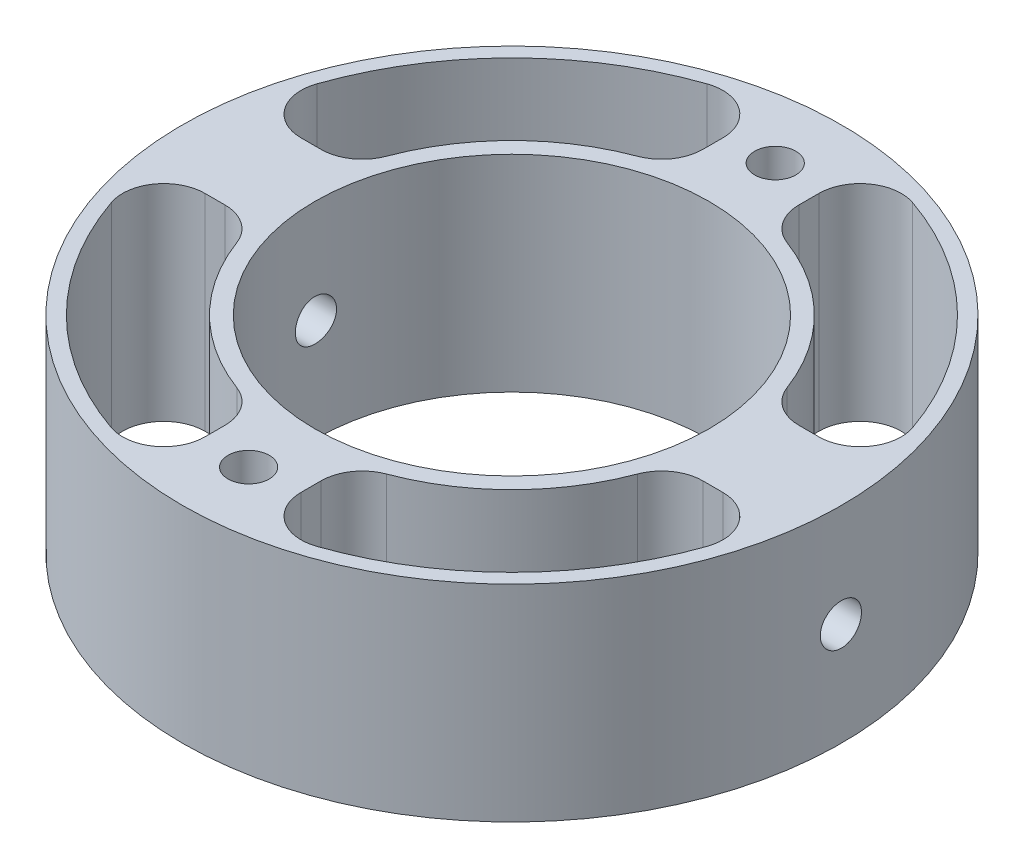
from build123d import *

# Parameters (mm, degrees)
SKETCH3_R           = 24
SKETCH3_R_2         = 14.35
BOSS_EXTRUDE1_DEPTH = 15
CUT_EXTRUDE2_START  = 50
SKETCH4_R           = 1.5
CUT_EXTRUDE2_DEPTH  = 100
SKETCH5_R           = 1.5
CUT_EXTRUDE3_DEPTH  = 100
CUT_EXTRUDE6_DEPTH  = 26
CUT_EXTRUDE7_DEPTH  = 26
CUT_EXTRUDE8_DEPTH  = 26
CUT_EXTRUDE9_DEPTH  = 26
FILLET5_R           = 3


with BuildPart() as part:
    # Sketch3 → Boss-Extrude1 (new body)
    with BuildSketch(Plane(origin=(0, 0, 0), x_dir=(1, 0, 0), z_dir=(0, 1, 0))):
        Circle(SKETCH3_R)
        Circle(SKETCH3_R_2, mode=Mode.SUBTRACT)
    extrude(amount=BOSS_EXTRUDE1_DEPTH)

    # Sketch4 → Cut-Extrude2 (cut)
    with BuildSketch(Plane(origin=(0, 0, 0), x_dir=(0, 0, -1), z_dir=(1, 0, 0)).offset(CUT_EXTRUDE2_START)):
        with Locations((0, 7.5)):
            Circle(SKETCH4_R)
    extrude(amount=-CUT_EXTRUDE2_DEPTH, mode=Mode.SUBTRACT)

    # Sketch5 → Cut-Extrude3 (cut)
    with BuildSketch(Plane(origin=(0, 15, 0), x_dir=(1, 0, 0), z_dir=(0, 1, 0))):
        with Locations((0, 19.175)):
            Circle(SKETCH5_R)
        with Locations((0, -19.175)):
            Circle(SKETCH5_R)
    extrude(amount=-CUT_EXTRUDE3_DEPTH, mode=Mode.SUBTRACT)

    # Sketch7 → Cut-Extrude6 (cut)
    with BuildSketch(Plane(origin=(0, 15, 0), x_dir=(1, 0, 0), z_dir=(0, 1, 0))):
        with BuildLine():
            Line((3.5, 15.175), (3.5, 22.675))
            ThreePointArc((3.5, 22.675), (16.223526512, 16.223526512), (22.675, 3.5))
            Line((22.675, 3.5), (15.175, 3.5))
            ThreePointArc((15.175, 3.5), (11.012053056, 11.012053056), (3.5, 15.175))
        make_face()
    extrude(amount=-CUT_EXTRUDE6_DEPTH, mode=Mode.SUBTRACT)

    # Sketch9 → Cut-Extrude7 (cut)
    with BuildSketch(Plane(origin=(0, 15, 0), x_dir=(1, 0, 0), z_dir=(0, 1, 0))):
        with BuildLine():
            Line((15.175, -3.5), (22.675, -3.5))
            ThreePointArc((22.675, -3.5), (16.223526512, -16.223526512), (3.5, -22.675))
            Line((3.5, -22.675), (3.5, -15.175))
            ThreePointArc((3.5, -15.175), (11.012053056, -11.012053056), (15.175, -3.5))
        make_face()
    extrude(amount=-CUT_EXTRUDE7_DEPTH, mode=Mode.SUBTRACT)

    # Sketch10 → Cut-Extrude8 (cut)
    with BuildSketch(Plane(origin=(0, 15, 0), x_dir=(1, 0, 0), z_dir=(0, 1, 0))):
        with BuildLine():
            Line((-3.5, 15.175), (-3.5, 22.675))
            ThreePointArc((-3.5, 22.675), (-16.223526512, 16.223526512), (-22.675, 3.5))
            Line((-22.675, 3.5), (-15.175, 3.5))
            ThreePointArc((-15.175, 3.5), (-11.012053056, 11.012053056), (-3.5, 15.175))
        make_face()
    extrude(amount=-CUT_EXTRUDE8_DEPTH, mode=Mode.SUBTRACT)

    # Sketch11 → Cut-Extrude9 (cut)
    with BuildSketch(Plane(origin=(0, 15, 0), x_dir=(1, 0, 0), z_dir=(0, 1, 0))):
        with BuildLine():
            Line((-15.175, -3.5), (-22.675, -3.5))
            ThreePointArc((-22.675, -3.5), (-16.223526512, -16.223526512), (-3.5, -22.675))
            Line((-3.5, -22.675), (-3.5, -15.175))
            ThreePointArc((-3.5, -15.175), (-11.012053056, -11.012053056), (-15.175, -3.5))
        make_face()
    extrude(amount=-CUT_EXTRUDE9_DEPTH, mode=Mode.SUBTRACT)

    # Fillet5
    fillet5_edges = [part.edges().sort_by_distance(p)[0] for p in [
        (-3.5, 7.5, 22.675),
        (-22.675, 7.5, 3.5),
        (-15.175, 7.5, 3.5),
        (-3.5, 7.5, 15.175),
        (3.5, 7.5, -22.675),
        (22.675, 7.5, -3.5),
        (15.175, 7.5, -3.5),
        (3.5, 7.5, -15.175),
        (3.5, 7.5, 15.175),
        (15.175, 7.5, 3.5),
        (22.675, 7.5, 3.5),
        (3.5, 7.5, 22.675),
        (-3.5, 7.5, -15.175),
        (-15.175, 7.5, -3.5),
        (-22.675, 7.5, -3.5),
        (-3.5, 7.5, -22.675),
    ]]
    fillet(fillet5_edges, radius=FILLET5_R)


solid = part.part
